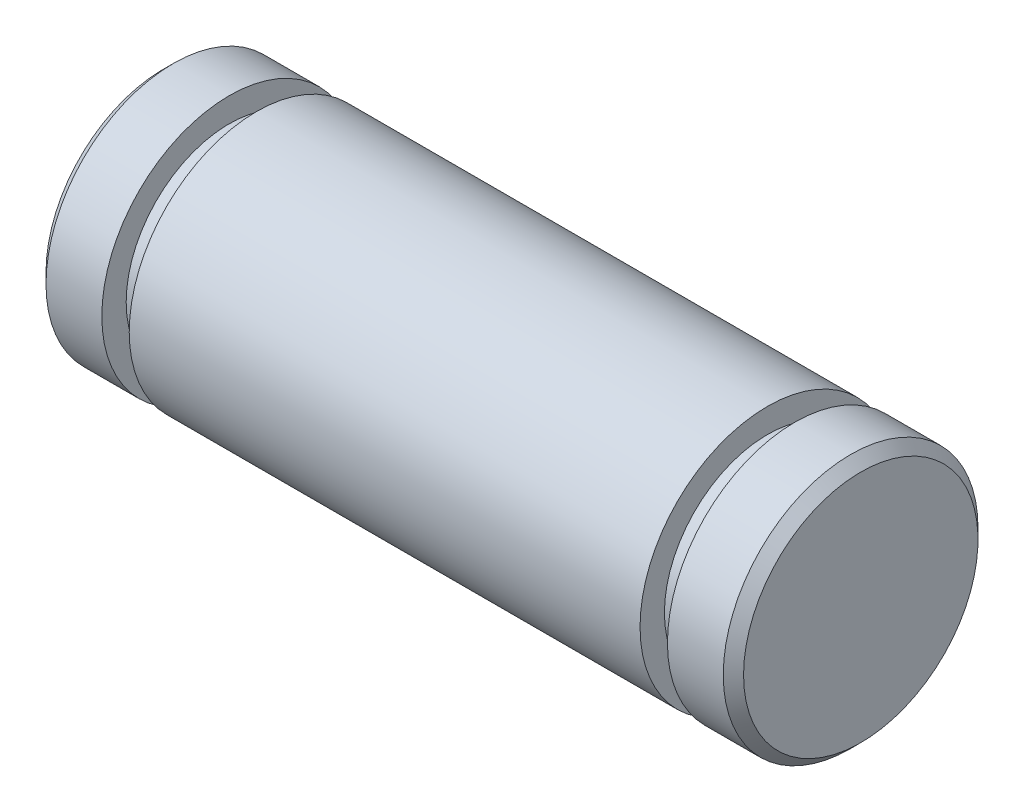
from build123d import *


with BuildPart() as part:
    # Sketch1 → Revolve1 (revolve)
    with BuildSketch(Plane.XY):
        Polygon((-13.0937, 0), (-13.0937, 4.40055), (-12.7127, 4.78155), (-10.6172, 4.78155), (-10.6172, 3.86715), (-9.5885, 3.86715), (-9.5885, 4.78155), (9.5885, 4.78155), (9.5885, 3.86715), (10.6172, 3.86715), (10.6172, 4.78155), (12.7127, 4.78155), (13.0937, 4.40055), (13.0937, 0), align=None)
    revolve(axis=Axis((13.0937, 0, 0), (-1, 0, 0)))


solid = part.part
